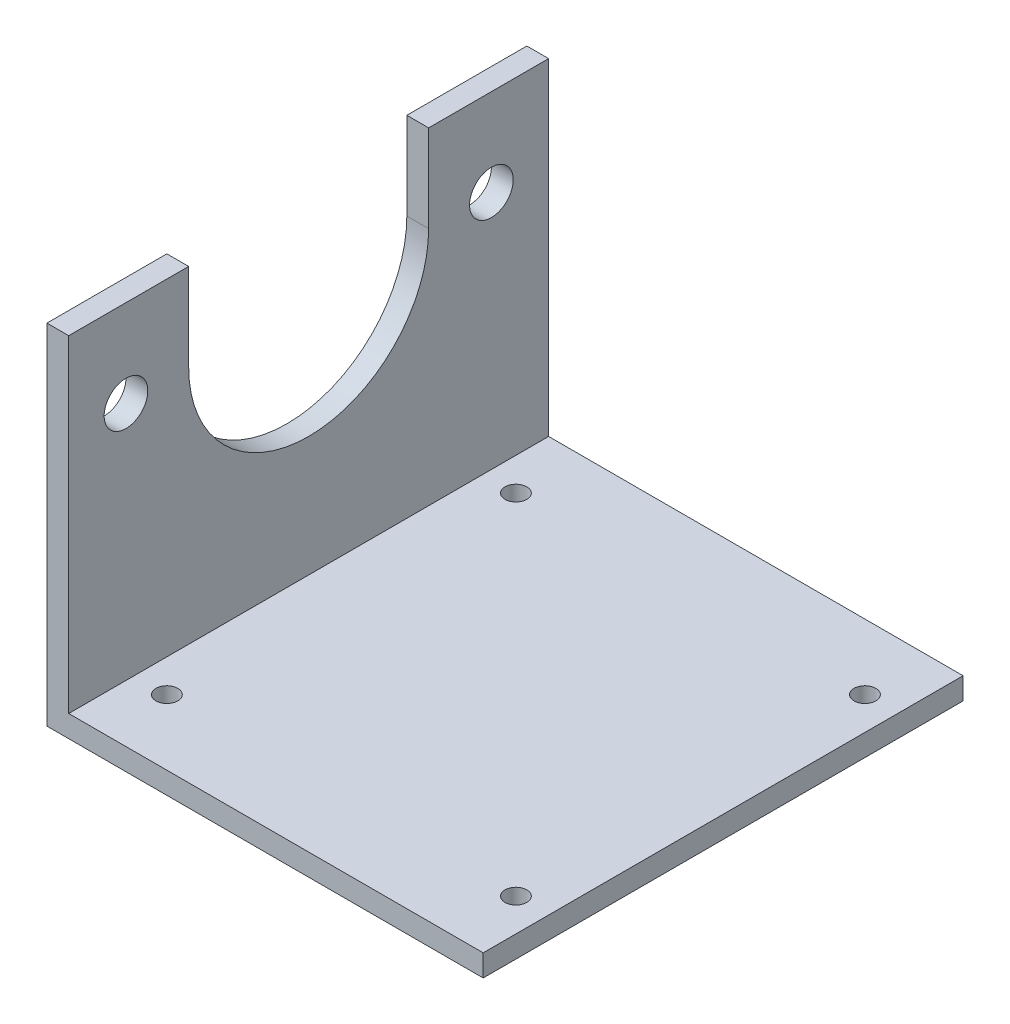
from build123d import *

# Parameters (mm, degrees)
BOSS_EXTRUDE1_DEPTH = 69.85
CUT_EXTRUDE1_REACH  = 8.35
SKETCH2_R           = 6.35
CUT_EXTRUDE2_REACH  = 8.35
SKETCH3_R           = 3.175


with BuildPart() as part:
    # Sketch1 → Boss-Extrude1 (new body, symmetric)
    with BuildSketch(Plane.XY):
        Polygon((0, 0), (0, 95.25), (-6.35, 95.25), (-6.35, -6.35), (120.65, -6.35), (120.65, 0), align=None)
    extrude(amount=BOSS_EXTRUDE1_DEPTH, both=True)

    # Sketch2 → Cut-Extrude1 (cut, up to next)
    with BuildSketch(Plane(origin=(0, 0, 0), x_dir=(0, 0, -1), z_dir=(1, 0, 0)), mode=Mode.PRIVATE) as cut_extrude1_sk1:
        with Locations((-53.1876, 69.85)):
            Circle(SKETCH2_R)
    cut_extrude1_tool1 = extrude(cut_extrude1_sk1.sketch, amount=-CUT_EXTRUDE1_REACH, mode=Mode.PRIVATE) & part.part
    add(cut_extrude1_tool1.solids().sort_by_distance((0, 69.85, 53.1876))[0], mode=Mode.SUBTRACT)
    # Sketch2 → Cut-Extrude1 (cut, up to next)
    with BuildSketch(Plane(origin=(0, 0, 0), x_dir=(0, 0, -1), z_dir=(1, 0, 0)), mode=Mode.PRIVATE) as cut_extrude1_sk2:
        with Locations((53.1876, 69.85)):
            Circle(SKETCH2_R)
    cut_extrude1_tool2 = extrude(cut_extrude1_sk2.sketch, amount=-CUT_EXTRUDE1_REACH, mode=Mode.PRIVATE) & part.part
    add(cut_extrude1_tool2.solids().sort_by_distance((0, 69.85, -53.1876))[0], mode=Mode.SUBTRACT)
    # Sketch2 → Cut-Extrude1 (cut, up to next)
    with BuildSketch(Plane(origin=(0, 0, 0), x_dir=(0, 0, -1), z_dir=(1, 0, 0)), mode=Mode.PRIVATE) as cut_extrude1_sk3:
        with BuildLine():
            Line((-34.925, 69.85), (-34.925, 95.25))
            Line((-34.925, 95.25), (34.925, 95.25))
            Line((34.925, 95.25), (34.925, 69.85))
            ThreePointArc((34.925, 69.85), (0, 34.925), (-34.925, 69.85))
        make_face()
    cut_extrude1_tool3 = extrude(cut_extrude1_sk3.sketch, amount=-CUT_EXTRUDE1_REACH, mode=Mode.PRIVATE) & part.part
    add(cut_extrude1_tool3.solids().sort_by_distance((0, 68.259897, 0))[0], mode=Mode.SUBTRACT)

    # Sketch3 → Cut-Extrude2 (cut, up to next)
    with BuildSketch(Plane(origin=(0, 0, 0), x_dir=(1, 0, 0), z_dir=(0, 1, 0)), mode=Mode.PRIVATE) as cut_extrude2_sk1:
        with Locations((9.525, 50.8)):
            Circle(SKETCH3_R)
    cut_extrude2_tool1 = extrude(cut_extrude2_sk1.sketch, amount=-CUT_EXTRUDE2_REACH, mode=Mode.PRIVATE) & part.part
    add(cut_extrude2_tool1.solids().sort_by_distance((9.525, 0, -50.8))[0], mode=Mode.SUBTRACT)
    # Sketch3 → Cut-Extrude2 (cut, up to next)
    with BuildSketch(Plane(origin=(0, 0, 0), x_dir=(1, 0, 0), z_dir=(0, 1, 0)), mode=Mode.PRIVATE) as cut_extrude2_sk2:
        with Locations((111.125, 50.8)):
            Circle(SKETCH3_R)
    cut_extrude2_tool2 = extrude(cut_extrude2_sk2.sketch, amount=-CUT_EXTRUDE2_REACH, mode=Mode.PRIVATE) & part.part
    add(cut_extrude2_tool2.solids().sort_by_distance((111.125, 0, -50.8))[0], mode=Mode.SUBTRACT)
    # Sketch3 → Cut-Extrude2 (cut, up to next)
    with BuildSketch(Plane(origin=(0, 0, 0), x_dir=(1, 0, 0), z_dir=(0, 1, 0)), mode=Mode.PRIVATE) as cut_extrude2_sk3:
        with Locations((9.525, -50.8)):
            Circle(SKETCH3_R)
    cut_extrude2_tool3 = extrude(cut_extrude2_sk3.sketch, amount=-CUT_EXTRUDE2_REACH, mode=Mode.PRIVATE) & part.part
    add(cut_extrude2_tool3.solids().sort_by_distance((9.525, 0, 50.8))[0], mode=Mode.SUBTRACT)
    # Sketch3 → Cut-Extrude2 (cut, up to next)
    with BuildSketch(Plane(origin=(0, 0, 0), x_dir=(1, 0, 0), z_dir=(0, 1, 0)), mode=Mode.PRIVATE) as cut_extrude2_sk4:
        with Locations((111.125, -50.8)):
            Circle(SKETCH3_R)
    cut_extrude2_tool4 = extrude(cut_extrude2_sk4.sketch, amount=-CUT_EXTRUDE2_REACH, mode=Mode.PRIVATE) & part.part
    add(cut_extrude2_tool4.solids().sort_by_distance((111.125, 0, 50.8))[0], mode=Mode.SUBTRACT)


solid = part.part
